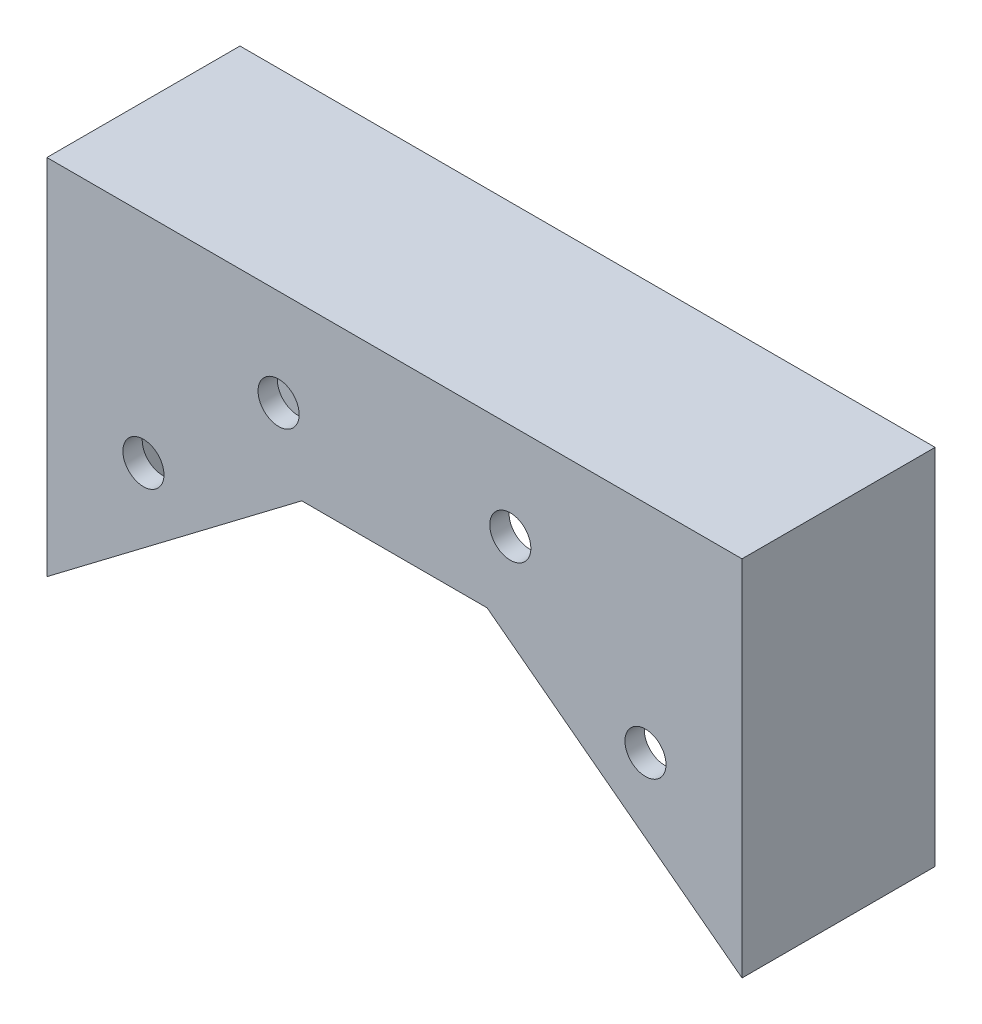
from build123d import *

# Parameters (mm, degrees)
BOSS_EXTRUDE2_DEPTH = 15.875
SHELL2_T            = -3.175
SKETCH3_R           = 3.3782
CUT_EXTRUDE1_DEPTH  = 32.75


with BuildPart() as part:
    # Sketch2 → Boss-Extrude2 (new body, symmetric)
    with BuildSketch(Plane.XY):
        Polygon((-15.24, 0), (15.24, 0), (57.15, -31.75), (57.15, 27.94), (-57.15, 27.94), (-57.15, -31.75), align=None)
    extrude(amount=BOSS_EXTRUDE2_DEPTH, both=True)

    # Shell2
    shell2_openings = [part.faces().sort_by_distance(p)[0] for p in [
        (36.195, -15.875, 0),
        (0, 0, 0),
        (-36.195, -15.875, 0),
    ]]
    offset(amount=SHELL2_T, openings=shell2_openings, kind=Kind.INTERSECTION)

    # Sketch3 → Cut-Extrude1 (cut, through all)
    with BuildSketch(Plane(origin=(0, 0, -15.875), x_dir=(-1, 0, 0), z_dir=(0, 0, -1))):
        with Locations((41.275, -7.62)):
            Circle(SKETCH3_R)
        with Locations((19.05, 12.065)):
            Circle(SKETCH3_R)
        with Locations((-19.05, 12.065)):
            Circle(SKETCH3_R)
        with Locations((-41.275, -7.62)):
            Circle(SKETCH3_R)
    extrude(amount=-CUT_EXTRUDE1_DEPTH, mode=Mode.SUBTRACT)


solid = part.part
